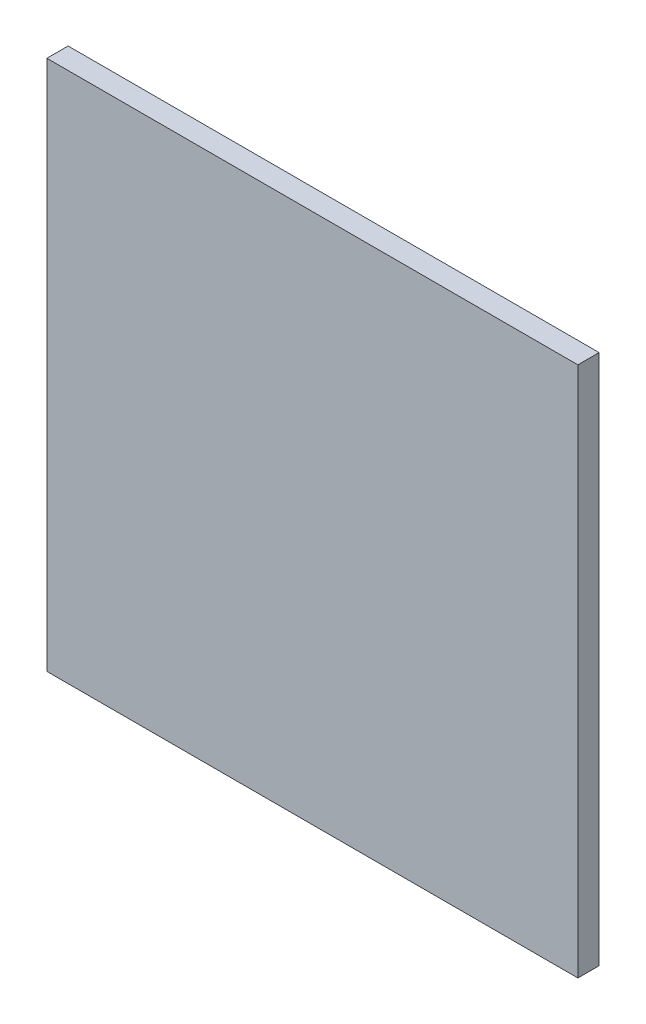
from build123d import *

# Parameters (mm, degrees)
SKETCH_1_W             = 250
SKETCH_1_H             = 250
EXTRUDE_1_DEPTH        = 10
SKETCH_4_R             = 8
EXTRUDE_2_DEPTH        = 4
SKETCH_6_R             = 1.5
EXTRUDE_3_DEPTH        = 3
PATTERN_LINEAR_1_COUNT = 6
PATTERN_LINEAR_1_PITCH = 30
DRAFT_1_ANGLE          = 30
PATTERN_LINEAR_2_COUNT = 6
PATTERN_LINEAR_2_PITCH = 30
DRAFT_2_ANGLE          = 30
DRAFT_3_ANGLE          = 30
DRAFT_4_ANGLE          = 30
DRAFT_5_ANGLE          = 30
DRAFT_6_ANGLE          = 30


with BuildPart() as part:
    # 草图1 → 凸台-拉伸1 (new body)
    with BuildSketch(Plane.XY):
        with Locations((16.726943942, -49.050632911)):
            Rectangle(SKETCH_1_W, SKETCH_1_H)
    extrude(amount=EXTRUDE_1_DEPTH)

    # 草图4 → 凸台-拉伸2 (add)
    with BuildSketch(Plane(origin=(0, 0, 0), x_dir=(-1, 0, 0), z_dir=(0, 0, -1))):
        with Locations((-24.479358253, -68.79415652)):
            Circle(SKETCH_4_R)
    extrude(amount=EXTRUDE_2_DEPTH)

    # 草图6 → 凸台-拉伸3 (add)
    with BuildSketch(Plane(origin=(0, 0, 0), x_dir=(-1, 0, 0), z_dir=(0, 0, -1))):
        with Locations((-128.994191702, 14.387355328)):
            Circle(SKETCH_6_R)
    extrude_3 = extrude(amount=EXTRUDE_3_DEPTH)

    # 阵列(线性)1: 凸台-拉伸3 ×6
    with Locations(*[(0, -i * PATTERN_LINEAR_1_PITCH, 0) for i in range(1, PATTERN_LINEAR_1_COUNT)]):
        add(extrude_3)

    # 拔模1
    draft_1_faces = [part.faces().sort_by_distance(p)[0] for p in [
        (130.494191702, 14.387355328, -1.5),
    ]]
    draft(draft_1_faces, Plane(origin=(128.994191702, 14.387355328, -3), x_dir=(-1, 0, 0), z_dir=(0, 0, -1)), DRAFT_1_ANGLE)

    # 阵列(线性)2: 凸台-拉伸3 ×6
    with Locations(*[(0, -i * PATTERN_LINEAR_2_PITCH, 0) for i in range(1, PATTERN_LINEAR_2_COUNT)]):
        add(extrude_3)

    # 拔模2
    draft_2_faces = [part.faces().sort_by_distance(p)[0] for p in [
        (130.494191702, -15.612644672, -1.5),
    ]]
    draft(draft_2_faces, Plane(origin=(128.994191702, -15.612644672, -3), x_dir=(-1, 0, 0), z_dir=(0, 0, -1)), DRAFT_2_ANGLE)

    # 拔模3
    draft_3_faces = [part.faces().sort_by_distance(p)[0] for p in [
        (130.494191702, -45.612644672, -1.5),
    ]]
    draft(draft_3_faces, Plane(origin=(128.994191702, -45.612644672, -3), x_dir=(-1, 0, 0), z_dir=(0, 0, -1)), DRAFT_3_ANGLE)

    # 拔模4
    draft_4_faces = [part.faces().sort_by_distance(p)[0] for p in [
        (130.494191702, -75.612644672, -1.5),
    ]]
    draft(draft_4_faces, Plane(origin=(128.994191702, -75.612644672, -3), x_dir=(-1, 0, 0), z_dir=(0, 0, -1)), DRAFT_4_ANGLE)

    # 拔模5
    draft_5_faces = [part.faces().sort_by_distance(p)[0] for p in [
        (130.494191702, -105.612644672, -1.5),
    ]]
    draft(draft_5_faces, Plane(origin=(128.994191702, -105.612644672, -3), x_dir=(-1, 0, 0), z_dir=(0, 0, -1)), DRAFT_5_ANGLE)

    # 拔模6
    draft_6_faces = [part.faces().sort_by_distance(p)[0] for p in [
        (130.494191702, -135.612644672, -1.5),
    ]]
    draft(draft_6_faces, Plane(origin=(128.994191702, -135.612644672, -3), x_dir=(-1, 0, 0), z_dir=(0, 0, -1)), DRAFT_6_ANGLE)


solid = part.part
